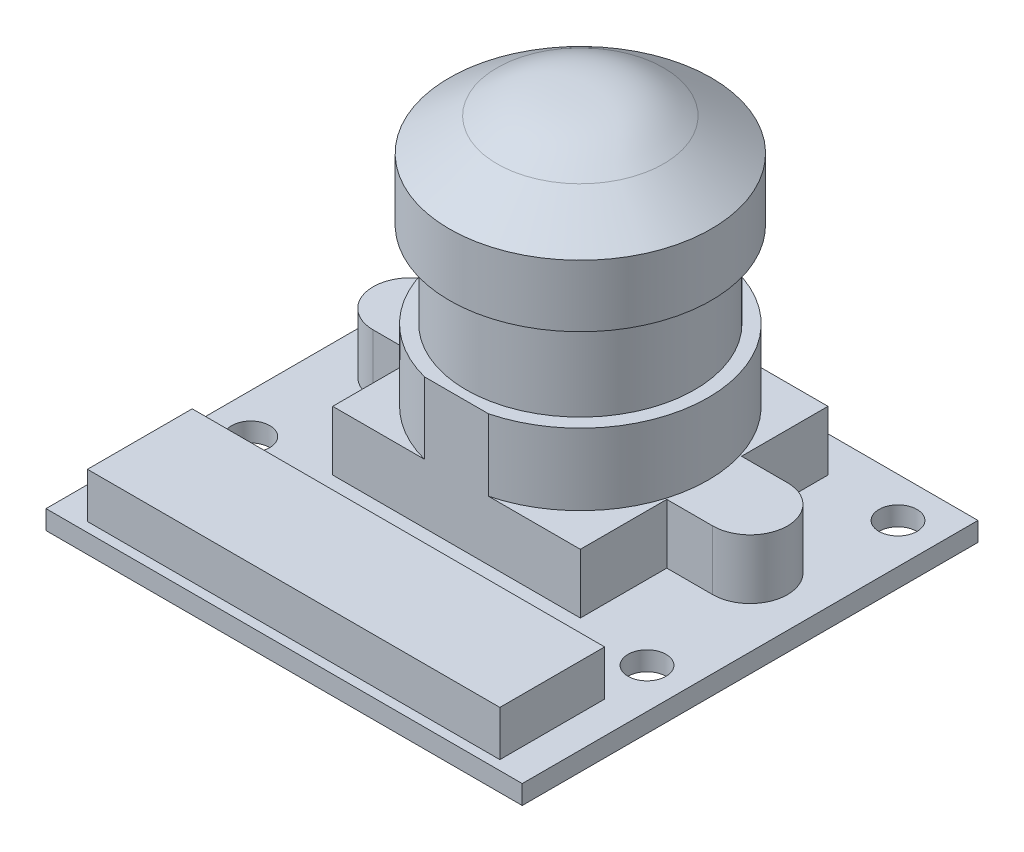
from build123d import *

# Parameters (mm, degrees)
SKETCH1_W           = 25.4
SKETCH1_H           = 24.3078
BOSS_EXTRUDE1_DEPTH = 1.016
SKETCH2_R           = 1.016
CUT_EXTRUDE1_DEPTH  = 10
SKETCH3_W           = 21.9964
SKETCH3_H           = 5.588
BOSS_EXTRUDE2_DEPTH = 2.413
BOSS_EXTRUDE3_DEPTH = 3.175
BOSS_EXTRUDE4_DEPTH = 3.81
SKETCH6_R           = 6.096408591
BOSS_EXTRUDE5_DEPTH = 4.572
SKETCH9_R           = 1.5621
BOSS_EXTRUDE6_DEPTH = 1.0668
FILLET1_R           = 0.25
SKETCH10_R          = 1
CUT_EXTRUDE2_DEPTH  = 1


with BuildPart() as part:
    # Sketch1 → Boss-Extrude1 (new body)
    with BuildSketch(Plane(origin=(0, 0, 0), x_dir=(1, 0, 0), z_dir=(0, 1, 0))):
        with Locations((4.969417476, -5.139336893)):
            Rectangle(SKETCH1_W, SKETCH1_H)
    extrude(amount=BOSS_EXTRUDE1_DEPTH)

    # Sketch2 → Cut-Extrude1 (cut)
    with BuildSketch(Plane(origin=(0, 1.016, 0), x_dir=(1, 0, 0), z_dir=(0, 1, 0))):
        with Locations((-5.596982524, 4.880963107)):
            Circle(SKETCH2_R)
        with Locations((-5.596982524, -8.504836893)):
            Circle(SKETCH2_R)
        with Locations((15.535817476, 4.880963107)):
            Circle(SKETCH2_R)
        with Locations((15.535817476, -8.504836893)):
            Circle(SKETCH2_R)
    extrude(amount=-CUT_EXTRUDE1_DEPTH, mode=Mode.SUBTRACT)

    # Sketch3 → Boss-Extrude2 (add)
    with BuildSketch(Plane(origin=(0, 1.016, 0), x_dir=(1, 0, 0), z_dir=(0, 1, 0))):
        with Locations((4.969417476, -13.991236893)):
            Rectangle(SKETCH3_W, SKETCH3_H)
    extrude(amount=BOSS_EXTRUDE2_DEPTH)

    # Sketch4 → Boss-Extrude3 (add)
    with BuildSketch(Plane(origin=(0, 1.016, 0), x_dir=(1, 0, 0), z_dir=(0, 1, 0))):
        with BuildLine():
            Line((-1.634582524, 5.109563107), (11.573417476, 5.109563107))
            Line((11.573417476, 5.109563107), (11.573417476, 0.499463107))
            Line((11.573417476, 0.499463107), (14.024517476, 0.499463107))
            ThreePointArc((14.024517476, 0.499463107), (16.018417476, -1.494436893), (14.024517476, -3.488336893))
            Line((14.024517476, -3.488336893), (11.573417476, -3.488336893))
            Line((11.573417476, -3.488336893), (11.573417476, -8.098436893))
            Line((11.573417476, -8.098436893), (-1.634582524, -8.098436893))
            Line((-1.634582524, -8.098436893), (-1.634582524, -3.488336893))
            Line((-1.634582524, -3.488336893), (-4.085682524, -3.488336893))
            ThreePointArc((-4.085682524, -3.488336893), (-6.079582524, -1.494436893), (-4.085682524, 0.499463107))
            Line((-4.085682524, 0.499463107), (-1.634582524, 0.499463107))
            Line((-1.634582524, 0.499463107), (-1.634582524, 5.109563107))
        make_face()
    extrude(amount=BOSS_EXTRUDE3_DEPTH)

    # Sketch5 → Boss-Extrude4 (add)
    with BuildSketch(Plane(origin=(0, 4.191, 0), x_dir=(1, 0, 0), z_dir=(0, 1, 0))):
        with BuildLine():
            Line((6.671833409, -8.098436893), (3.267001542, -8.098436893))
            ThreePointArc((3.267001542, -8.098436893), (-1.850482524, -1.494436893), (3.267001542, 5.109563107))
            Line((3.267001542, 5.109563107), (4.969417476, 5.109563107))
            Line((4.969417476, 5.109563107), (6.671833409, 5.109563107))
            ThreePointArc((6.671833409, 5.109563107), (11.789317476, -1.494436893), (6.671833409, -8.098436893))
        make_face()
    extrude(amount=BOSS_EXTRUDE4_DEPTH)

    # Sketch6 → Boss-Extrude5 (add)
    with BuildSketch(Plane(origin=(0, 8.001, 0), x_dir=(1, 0, 0), z_dir=(0, 1, 0))):
        with Locations((4.969417476, -1.494436893)):
            Circle(SKETCH6_R)
    extrude(amount=BOSS_EXTRUDE5_DEPTH)

    # Sketch8 → Revolve1 (revolve)
    with BuildSketch(Plane(origin=(4.969417476, 12.573, 1.494436893), x_dir=(0, 0, 1), z_dir=(-1, 0, 0))):
        with BuildLine():
            Line((-4.44130706, 5.035394986), (-6.985, 3.302))
            Line((-6.985, 3.302), (-6.985, 0))
            Line((-6.985, 0), (0, 0))
            Line((0, 0), (0, 6.35))
            add(Edge.make_bspline(
                [(0, 6.35), (-2.343173103, 6.35), (-3.129648943, 5.88240785), (-4.44130706, 5.035394986)],
                knots=[0, 0, 0, 0, 1, 1, 1, 1], degree=3))
        make_face()
    revolve(axis=Axis((4.969417476, 12.573, 1.494436893), (0, 1, 0)))

    # Sketch9 → Boss-Extrude6 (add)
    with BuildSketch(Plane.XZ):
        with Locations((14.430917476, 1.659536893)):
            Circle(SKETCH9_R)
        with Locations((-4.492082524, 1.659536893)):
            Circle(SKETCH9_R)
    extrude(amount=BOSS_EXTRUDE6_DEPTH)

    # Fillet1
    fillet1_edges = [part.edges().sort_by_distance(p)[0] for p in [
        (12.868817476, -1.0668, 1.659536893),
        (-6.054182524, -1.0668, 1.659536893),
    ]]
    fillet(fillet1_edges, radius=FILLET1_R)

    # Sketch10 → Cut-Extrude2 (cut)
    with BuildSketch(Plane.XZ):
        with Locations((4.969417476, 5.139336893)):
            Circle(SKETCH10_R)
    extrude(amount=-CUT_EXTRUDE2_DEPTH, mode=Mode.SUBTRACT)


solid = part.part
